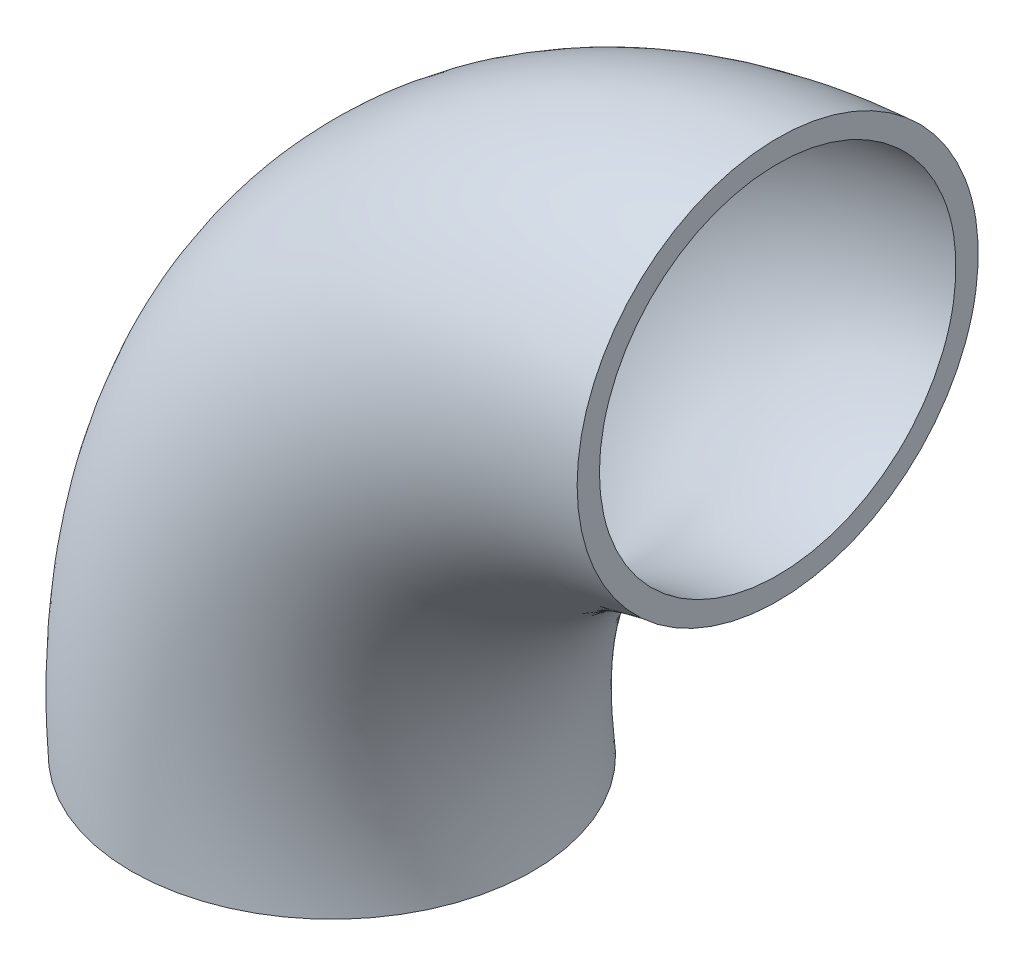
from build123d import *

# Parameters (mm, degrees)
CROQUIS1_R   = 18
CROQUIS1_R_2 = 16


with BuildPart() as part:
    # Barrer1: sweep along a path in Croquis2
    with BuildLine(Plane.XY) as barrer1_path:
        ThreePointArc((0, 0), (9.644660941, 33.284271247), (40, 50))
    # Croquis1 → Barrer1 (sweep)
    with BuildSketch(Plane(origin=(0, 0, 0), x_dir=(1, 0, 0), z_dir=(0, 1, 0))):
        Circle(CROQUIS1_R)
        Circle(CROQUIS1_R_2, mode=Mode.SUBTRACT)
    sweep(path=barrer1_path.line)


solid = part.part
